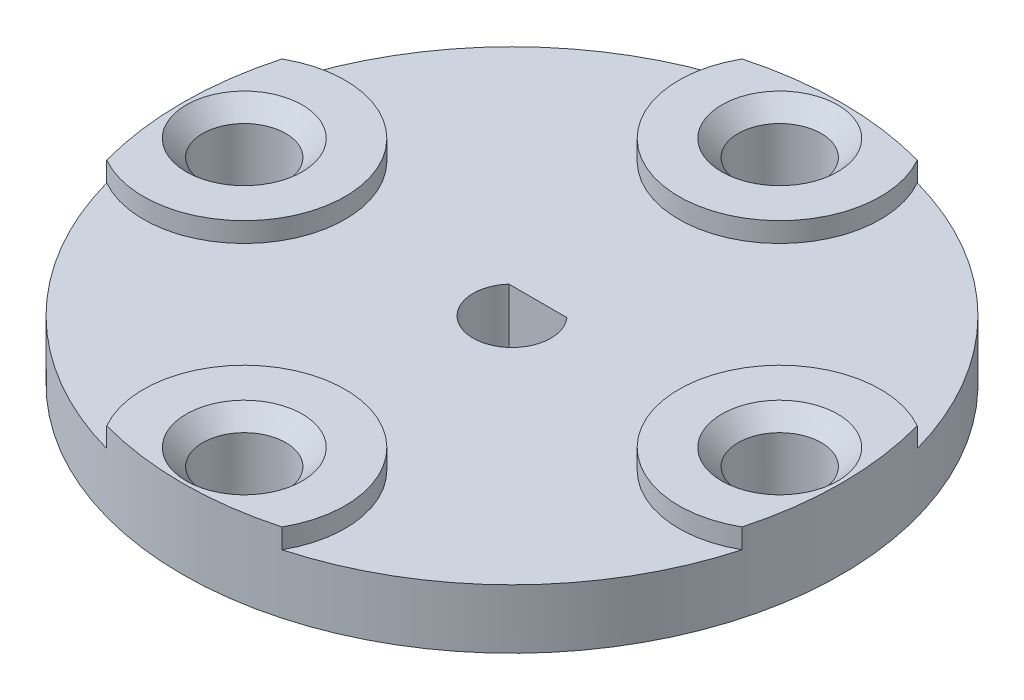
from build123d import *

# Parameters (mm, degrees)
SKETCH1_R           = 12.7
BOSS_EXTRUDE1_DEPTH = 2.286
SKETCH2_R           = 1.6002
CUT_EXTRUDE1_DEPTH  = 3.286
CIRPATTERN1_COUNT   = 4
SKETCH4_R           = 1.6002
BOSS_EXTRUDE3_DEPTH = 0.762
CHAMFER1_SIZE       = 0.635
SKETCH5_R           = 3.0861
BOSS_EXTRUDE4_DEPTH = 0.9525
CHAMFER2_SIZE       = 0.635


with BuildPart() as part:
    # Sketch1 → Boss-Extrude1 (new body)
    with BuildSketch(Plane(origin=(0, 0, 0), x_dir=(1, 0, 0), z_dir=(0, 1, 0))):
        Circle(SKETCH1_R)
        with BuildLine():
            Line((-1.1176, 0.998384796), (1.1176, 0.998384796))
            ThreePointArc((1.1176, 0.998384796), (0, -1.4986), (-1.1176, 0.998384796))
        make_face(mode=Mode.SUBTRACT)
    extrude(amount=BOSS_EXTRUDE1_DEPTH)

    # Sketch2 → Cut-Extrude1 (cut, through all)
    with BuildSketch(Plane(origin=(0, 2.286, 0), x_dir=(1, 0, 0), z_dir=(0, 1, 0))):
        with Locations((-10.31875, 0)):
            Circle(SKETCH2_R)
    cut_extrude1 = extrude(amount=-CUT_EXTRUDE1_DEPTH, mode=Mode.SUBTRACT)

    # CirPattern1: Cut-Extrude1 ×4 about axis
    cirpattern1_axis = Axis((0, 0, 0), (0, 1, 0))
    for i in range(1, CIRPATTERN1_COUNT):
        add(cut_extrude1.rotate(cirpattern1_axis, i * 360 / CIRPATTERN1_COUNT), mode=Mode.SUBTRACT)

    # Sketch4 → Boss-Extrude3 (add)
    with BuildSketch(Plane(origin=(0, 2.286, 0), x_dir=(1, 0, 0), z_dir=(0, 1, 0))):
        with BuildLine():
            ThreePointArc((-12.242958262, -3.376384606), (-6.43255, 0), (-12.242958262, 3.376384606))
            ThreePointArc((-12.242958262, 3.376384606), (-12.7, 0), (-12.242958262, -3.376384606))
        make_face()
        with Locations((-10.31875, 0)):
            Circle(SKETCH4_R, mode=Mode.SUBTRACT)
        with BuildLine():
            ThreePointArc((-3.376384606, 12.242958262), (0, 6.43255), (3.376384606, 12.242958262))
            ThreePointArc((3.376384606, 12.242958262), (0, 12.7), (-3.376384606, 12.242958262))
        make_face()
        with Locations((0, 10.31875)):
            Circle(SKETCH4_R, mode=Mode.SUBTRACT)
        with BuildLine():
            ThreePointArc((12.242958262, 3.376384606), (6.43255, 0), (12.242958262, -3.376384606))
            ThreePointArc((12.242958262, -3.376384606), (12.7, 0), (12.242958262, 3.376384606))
        make_face()
        with Locations((10.31875, 0)):
            Circle(SKETCH4_R, mode=Mode.SUBTRACT)
        with BuildLine():
            ThreePointArc((3.376384606, -12.242958262), (0, -6.43255), (-3.376384606, -12.242958262))
            ThreePointArc((-3.376384606, -12.242958262), (0, -12.7), (3.376384606, -12.242958262))
        make_face()
        with Locations((0, -10.31875)):
            Circle(SKETCH4_R, mode=Mode.SUBTRACT)
    extrude(amount=BOSS_EXTRUDE3_DEPTH)

    # Chamfer1
    chamfer1_edges = [part.edges().sort_by_distance(p)[0] for p in [
        (-1.6002, 3.048, -10.31875),
        (8.71855, 3.048, 0),
        (-11.91895, 3.048, 0),
        (-1.6002, 3.048, 10.31875),
    ]]
    chamfer(chamfer1_edges, length=CHAMFER1_SIZE)

    # Sketch5 → Boss-Extrude4 (add)
    with BuildSketch(Plane.XZ):
        Circle(SKETCH5_R)
        with BuildLine():
            Line((1.1176, -0.998384796), (-1.1176, -0.998384796))
            ThreePointArc((-1.1176, -0.998384796), (0, 1.4986), (1.1176, -0.998384796))
        make_face(mode=Mode.SUBTRACT)
    extrude(amount=BOSS_EXTRUDE4_DEPTH)

    # Chamfer2
    chamfer2_edges = [part.edges().sort_by_distance(p)[0] for p in [
        (-3.0861, -0.9525, 0),
    ]]
    chamfer(chamfer2_edges, length=CHAMFER2_SIZE)


solid = part.part
